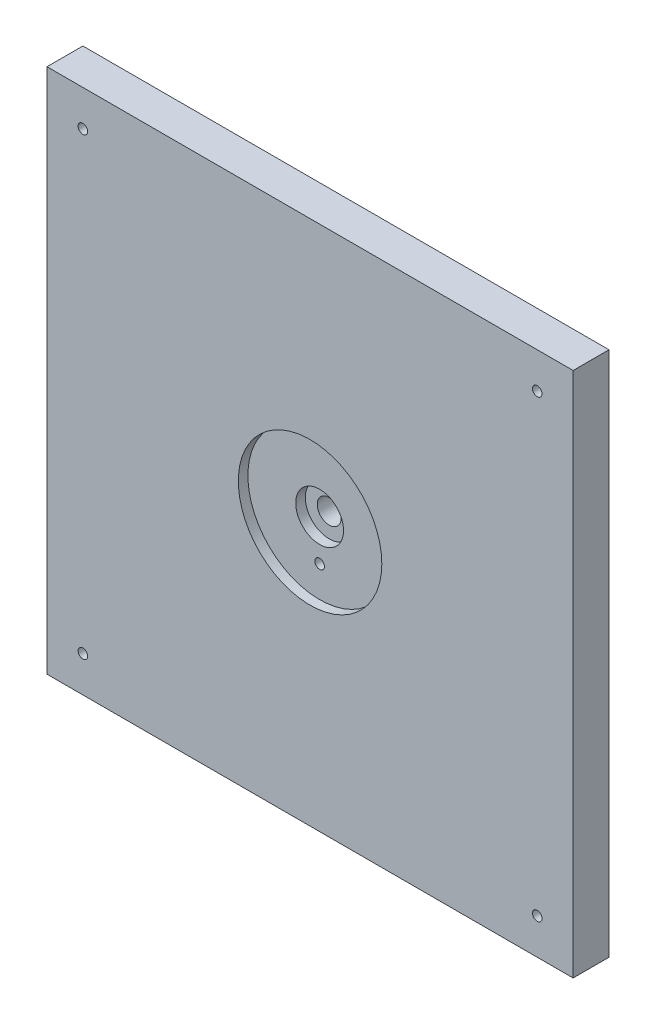
from build123d import *

# Parameters (mm, degrees)
SKETCH2_W           = 279.4
SKETCH2_H           = 279.4
BOSS_EXTRUDE1_DEPTH = 19.05
SKETCH6_R           = 12.7
CUT_EXTRUDE3_DEPTH  = 10.16
SKETCH8_R           = 38.1
CUT_EXTRUDE4_DEPTH  = 5.08
SKETCH9_R           = 6.35
CUT_EXTRUDE5_DEPTH  = 39.37
SKETCH10_R          = 2.54
CUT_EXTRUDE6_DEPTH  = 39.37
SKETCH11_R          = 2.54
CUT_EXTRUDE7_DEPTH  = 36.576


with BuildPart() as part:
    # Sketch2 → Boss-Extrude1 (new body)
    with BuildSketch(Plane.XY):
        Rectangle(SKETCH2_W, SKETCH2_H)
    extrude(amount=BOSS_EXTRUDE1_DEPTH)

    # Sketch6 → Cut-Extrude3 (cut)
    with BuildSketch(Plane.XY.offset(19.05)):
        Circle(SKETCH6_R)
    extrude(amount=-CUT_EXTRUDE3_DEPTH, mode=Mode.SUBTRACT)

    # Sketch8 → Cut-Extrude4 (cut)
    with BuildSketch(Plane.XY.offset(19.05)):
        Circle(SKETCH8_R)
    extrude(amount=-CUT_EXTRUDE4_DEPTH, mode=Mode.SUBTRACT)

    # Sketch9 → Cut-Extrude5 (cut)
    with BuildSketch(Plane.XY.offset(8.89)):
        Circle(SKETCH9_R)
    extrude(amount=-CUT_EXTRUDE5_DEPTH, mode=Mode.SUBTRACT)

    # Sketch10 → Cut-Extrude6 (cut)
    with BuildSketch(Plane.XY.offset(19.05)):
        with Locations((-120.65, -120.65)):
            Circle(SKETCH10_R)
        with Locations((-120.65, 120.65)):
            Circle(SKETCH10_R)
        with Locations((120.65, 120.65)):
            Circle(SKETCH10_R)
        with Locations((120.65, -120.65)):
            Circle(SKETCH10_R)
    extrude(amount=-CUT_EXTRUDE6_DEPTH, mode=Mode.SUBTRACT)

    # Sketch11 → Cut-Extrude7 (cut)
    with BuildSketch(Plane.XY.offset(19.05)):
        with Locations((0, -21.59)):
            Circle(SKETCH11_R)
    extrude(amount=-CUT_EXTRUDE7_DEPTH, mode=Mode.SUBTRACT)


solid = part.part
